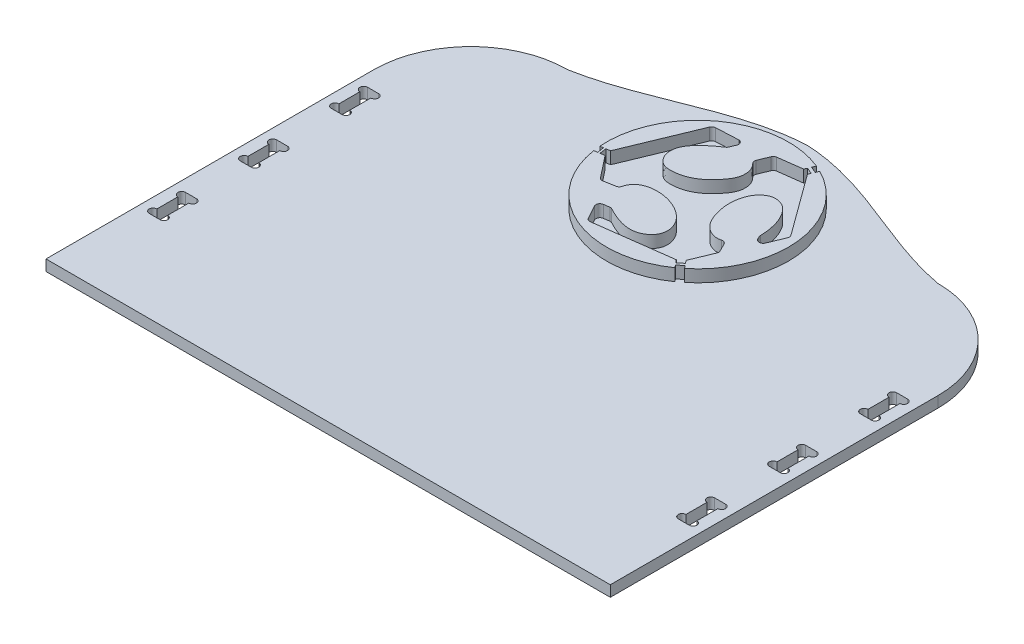
from build123d import *

# Parameters (mm, degrees)
BOSS_EXTRUDE1_DEPTH = 18
BOSS_EXTRUDE3_DEPTH = 20


with BuildPart() as part:
    # Sketch3 → Boss-Extrude1 (new body)
    with BuildSketch(Plane(origin=(0, 0, 0), x_dir=(1, 0, 0), z_dir=(0, 1, 0))):
        with BuildLine():
            Line((0, 0), (-930, 0))
            Line((-930, 0), (-930, 540))
            ThreePointArc((-930, 540), (-883.13708499, 653.13708499), (-770, 700))
            add(Edge.make_bspline(
                [(-770, 700), (-664.69635322, 719.084597111), (-573.996492447, 783.951968622), (-465, 789.509158613)],
                knots=[0, 0, 0, 0, 1, 1, 1, 1], degree=3))
            add(Edge.make_bspline(
                [(-160, 700), (-265.30364678, 719.084597111), (-356.003507553, 783.951968622), (-465, 789.509158613)],
                knots=[0, 0, 0, 0, 1, 1, 1, 1], degree=3))
            ThreePointArc((-160, 700), (-46.86291501, 653.13708499), (0, 540))
            Line((0, 540), (0, 0))
        make_face()
        with BuildLine():
            Line((-20, 150), (-38, 150))
            ThreePointArc((-38, 150), (-44.35, 156.35), (-38, 162.7))
            Line((-38, 162.7), (-38, 197.3))
            ThreePointArc((-38, 197.3), (-44.35, 203.65), (-38, 210))
            Line((-38, 210), (-20, 210))
            ThreePointArc((-20, 210), (-13.65, 203.65), (-20, 197.3))
            Line((-20, 197.3), (-20, 162.7))
            ThreePointArc((-20, 162.7), (-13.65, 156.35), (-20, 150))
        make_face(mode=Mode.SUBTRACT)
        with BuildLine():
            Line((-910, 450), (-892, 450))
            ThreePointArc((-892, 450), (-885.65, 456.35), (-892, 462.7))
            Line((-892, 462.7), (-892, 497.3))
            ThreePointArc((-892, 497.3), (-885.65, 503.65), (-892, 510))
            Line((-892, 510), (-910, 510))
            ThreePointArc((-910, 510), (-916.35, 503.65), (-910, 497.3))
            Line((-910, 497.3), (-910, 462.7))
            ThreePointArc((-910, 462.7), (-916.35, 456.35), (-910, 450))
        make_face(mode=Mode.SUBTRACT)
        with BuildLine():
            Line((-910, 300), (-892, 300))
            ThreePointArc((-892, 300), (-885.65, 306.35), (-892, 312.7))
            Line((-892, 312.7), (-892, 347.3))
            ThreePointArc((-892, 347.3), (-885.65, 353.65), (-892, 360))
            Line((-892, 360), (-910, 360))
            ThreePointArc((-910, 360), (-916.35, 353.65), (-910, 347.3))
            Line((-910, 347.3), (-910, 312.7))
            ThreePointArc((-910, 312.7), (-916.35, 306.35), (-910, 300))
        make_face(mode=Mode.SUBTRACT)
        with BuildLine():
            Line((-910, 150), (-892, 150))
            ThreePointArc((-892, 150), (-885.65, 156.35), (-892, 162.7))
            Line((-892, 162.7), (-892, 197.3))
            ThreePointArc((-892, 197.3), (-885.65, 203.65), (-892, 210))
            Line((-892, 210), (-910, 210))
            ThreePointArc((-910, 210), (-916.35, 203.65), (-910, 197.3))
            Line((-910, 197.3), (-910, 162.7))
            ThreePointArc((-910, 162.7), (-916.35, 156.35), (-910, 150))
        make_face(mode=Mode.SUBTRACT)
        with BuildLine():
            Line((-38, 312.7), (-38, 347.3))
            ThreePointArc((-38, 347.3), (-44.35, 353.65), (-38, 360))
            Line((-38, 360), (-20, 360))
            ThreePointArc((-20, 360), (-13.65, 353.65), (-20, 347.3))
            Line((-20, 347.3), (-20, 312.7))
            ThreePointArc((-20, 312.7), (-13.65, 306.35), (-20, 300))
            Line((-20, 300), (-38, 300))
            ThreePointArc((-38, 300), (-44.35, 306.35), (-38, 312.7))
        make_face(mode=Mode.SUBTRACT)
        with BuildLine():
            Line((-20, 450), (-38, 450))
            ThreePointArc((-38, 450), (-44.35, 456.35), (-38, 462.7))
            Line((-38, 462.7), (-38, 497.3))
            ThreePointArc((-38, 497.3), (-44.35, 503.65), (-38, 510))
            Line((-38, 510), (-20, 510))
            ThreePointArc((-20, 510), (-13.65, 503.65), (-20, 497.3))
            Line((-20, 497.3), (-20, 462.7))
            ThreePointArc((-20, 462.7), (-13.65, 456.35), (-20, 450))
        make_face(mode=Mode.SUBTRACT)
    extrude(amount=BOSS_EXTRUDE1_DEPTH)

    # Sketch4 → Boss-Extrude3 (add)
    with BuildSketch(Plane(origin=(0, 18, 0), x_dir=(1, 0, 0), z_dir=(0, 1, 0))):
        with BuildLine():
            Line((-379.222882365, 485.717294758), (-382.737003031, 490.02028309))
            Line((-382.737003031, 490.02028309), (-373.95352551, 497.187167352))
            Line((-373.95352551, 497.187167352), (-370.170166428, 492.550417512))
            ThreePointArc((-370.170166428, 492.550417512), (-315.881947929, 625.006423951), (-397.403737413, 742.675460443))
            Line((-397.403737413, 742.675460443), (-399.595153576, 737.371427218))
            Line((-399.595153576, 737.371427218), (-410.077786811, 741.702435514))
            Line((-410.077786811, 741.702435514), (-407.722392765, 747.403355536))
            ThreePointArc((-407.722392765, 747.403355536), (-553.118476248, 730.158011216), (-614.556786971, 597.256705849))
            Line((-614.556786971, 597.256705849), (-609.305354492, 598.063637084))
            Line((-609.305354492, 598.063637084), (-607.58398502, 586.861126686))
            Line((-607.58398502, 586.861126686), (-613.25925572, 585.989068783))
            ThreePointArc((-613.25925572, 585.989068783), (-524.072934254, 470.893038587), (-379.222882365, 485.717294758))
        make_face()
        with BuildLine():
            Line((-605.954754503, 598.578487803), (-604.233385032, 587.375977405))
            Line((-604.233385032, 587.375977405), (-597.029293803, 588.482952741))
            Line((-597.029293803, 588.482952741), (-568.840566092, 552.629818575))
            ThreePointArc((-568.840566092, 552.629818575), (-566.026361545, 550.558864621), (-562.547777239, 550.230156949))
            Line((-562.547777239, 550.230156949), (-544.012184687, 553.5242975))
            ThreePointArc((-544.012184687, 553.5242975), (-540.701764813, 555.173597747), (-538.813218815, 558.353607977))
            add(Edge.make_bspline(
                [(-538.813218815, 558.353607977), (-534.297460402, 576.070334999), (-503.019078365, 584.719773706), (-464.685769523, 573.113632357), (-440.044169756, 551.361798965), (-435.372177088, 522.801108934), (-465.299141833, 494.166605222), (-498.623668355, 508.836515007), (-515.396755845, 517.710933859)],
                knots=[0.009911477, 0.009911477, 0.009911477, 0.009911477, 0.210711156, 0.384962621, 0.515680366, 0.61771746, 0.71863394, 0.985505172, 0.985505172, 0.985505172, 0.985505172], degree=3))
            ThreePointArc((-515.396755845, 517.710933859), (-517.304141637, 518.368440775), (-519.321159046, 518.414011368))
            Line((-519.321159046, 518.414011368), (-528.660749273, 517.173060959))
            ThreePointArc((-528.660749273, 517.173060959), (-533.640663746, 513.638476733), (-533.538280042, 507.532549172))
            Line((-533.538280042, 507.532549172), (-521.15107554, 484.961134511))
            ThreePointArc((-521.15107554, 484.961134511), (-518.367019202, 482.26890411), (-514.548775713, 481.620759927))
            Line((-514.548775713, 481.620759927), (-389.451748889, 498.242389225))
            Line((-389.451748889, 498.242389225), (-385.513228418, 493.419729662))
            Line((-385.513228418, 493.419729662), (-376.731376811, 500.591602748))
            Line((-376.731376811, 500.591602748), (-380.563507134, 505.28812488))
            Line((-380.563507134, 505.28812488), (-365.655848241, 541.370143173))
            ThreePointArc((-365.655848241, 541.370143173), (-365.165238954, 544.139540747), (-365.881745133, 546.85926119))
            Line((-365.881745133, 546.85926119), (-372.699432744, 560.146905814))
            ThreePointArc((-372.699432744, 560.146905814), (-375.904525506, 563.158238505), (-380.291797246, 563.462525982))
            add(Edge.make_bspline(
                [(-380.291797246, 563.462525982), (-389.62136338, 560.847813387), (-407.34030176, 567.487642274), (-419.84509917, 588.039259046), (-426.364337105, 610.176048947), (-426.75390148, 634.572716458), (-418.374308101, 656.599818062), (-401.385797189, 668.865586287), (-379.856576304, 666.13746701), (-359.465829462, 641.758569228), (-355.228193135, 617.579148091), (-354.680419376, 601.80580369)],
                knots=[0.0061934, 0.0061934, 0.0061934, 0.0061934, 0.129362399, 0.215046737, 0.307702519, 0.422372662, 0.521838861, 0.597629821, 0.671660902, 0.77578766, 0.978099053, 0.978099053, 0.978099053, 0.978099053], degree=3))
            ThreePointArc((-354.680419376, 601.80580369), (-354.473650835, 600.385356434), (-353.962320397, 599.044101492))
            Line((-353.962320397, 599.044101492), (-351.783279864, 594.797160611))
            ThreePointArc((-351.783279864, 594.797160611), (-345.688613875, 591.244158092), (-339.906500201, 595.285932686))
            Line((-339.906500201, 595.285932686), (-329.168313442, 621.276294679))
            ThreePointArc((-329.168313442, 621.276294679), (-328.718783675, 624.556387197), (-329.931425401, 627.637066339))
            Line((-329.931425401, 627.637066339), (-403.370553681, 728.233570185))
            Line((-403.370553681, 728.233570185), (-401.527937134, 732.693380033))
            Line((-401.527937134, 732.693380033), (-412.01057037, 737.024388329))
            Line((-412.01057037, 737.024388329), (-413.853186916, 732.564578481))
            Line((-413.853186916, 732.564578481), (-453.198107375, 727.394628039))
            ThreePointArc((-453.198107375, 727.394628039), (-456.332644817, 726.096116164), (-458.396434076, 723.403119327))
            Line((-458.396434076, 723.403119327), (-465.579522616, 706.017402764))
            ThreePointArc((-465.579522616, 706.017402764), (-465.917084215, 702.084917604), (-463.932980801, 698.672920972))
            add(Edge.make_bspline(
                [(-463.932980801, 698.672920972), (-456.316914214, 691.747841587), (-451.453700795, 670.847901054), (-468.128106478, 647.707017887), (-487.409129401, 628.723458004), (-512.02899646, 620.595846866), (-535.731034887, 620.753825005), (-548.494456823, 635.551717206), (-553.67838325, 668.726301345), (-523.496250086, 689.825139347), (-509.375871044, 699.500113635)],
                knots=[0.010513604, 0.010513604, 0.010513604, 0.010513604, 0.140440996, 0.245214617, 0.361326435, 0.482761337, 0.571282501, 0.643749642, 0.712105448, 0.981383935, 0.981383935, 0.981383935, 0.981383935], degree=3))
            ThreePointArc((-509.375871044, 699.500113635), (-507.989430568, 700.779548939), (-507.02535105, 702.401190876))
            Line((-507.02535105, 702.401190876), (-503.168441841, 711.736329924))
            ThreePointArc((-503.168441841, 711.736329924), (-503.864230082, 718.003151755), (-509.526748851, 720.776788059))
            Line((-509.526748851, 720.776788059), (-545.744632169, 719.076899224))
            ThreePointArc((-545.744632169, 719.076899224), (-549.204312297, 717.892164096), (-551.489001713, 715.036787031))
            Line((-551.489001713, 715.036787031), (-599.174501495, 599.620336472))
            Line((-599.174501495, 599.620336472), (-605.954754503, 598.578487803))
        make_face(mode=Mode.SUBTRACT)
    extrude(amount=BOSS_EXTRUDE3_DEPTH)


solid = part.part
